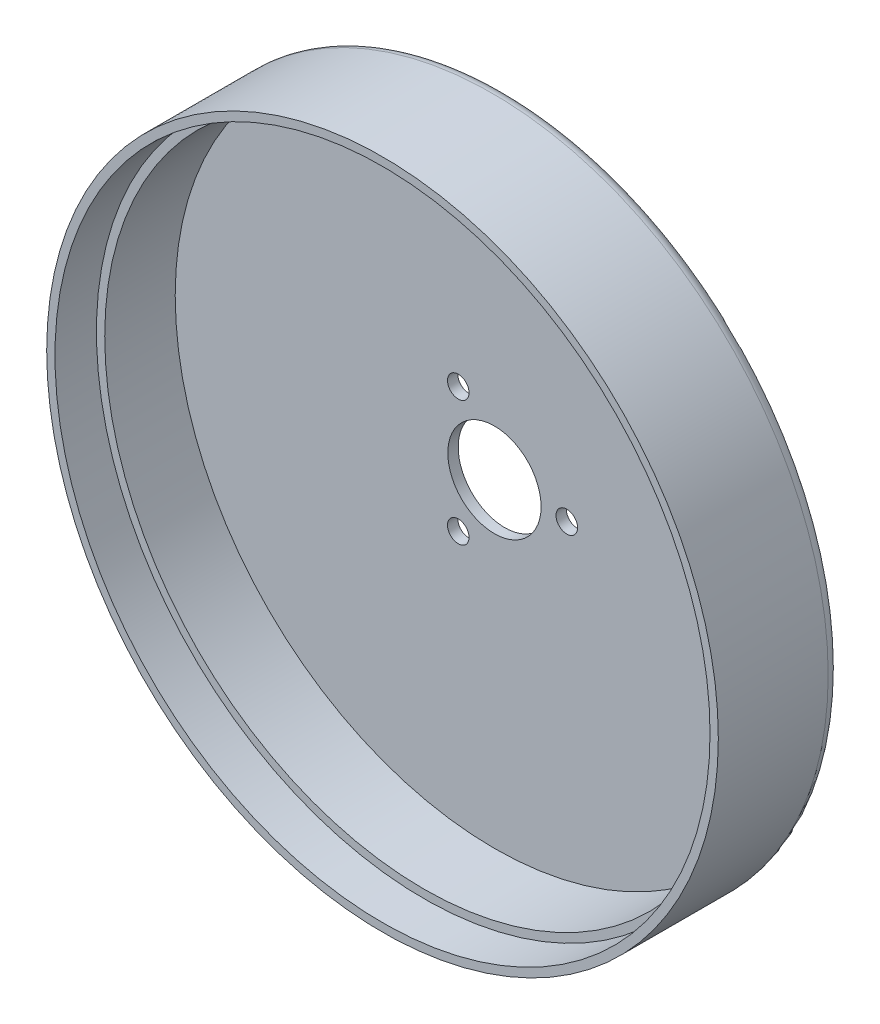
from build123d import *

# Parameters (mm, degrees)
SKETCH1_R           = 81
BOSS_EXTRUDE1_DEPTH = 2.5
SKETCH2_R           = 11.25
CUT_EXTRUDE1_DEPTH  = 3.5
SKETCH3_R           = 2.6
CUT_EXTRUDE2_DEPTH  = 3.5
SKETCH4_R           = 81
SKETCH4_R_2         = 77
BOSS_EXTRUDE2_DEPTH = 27
SKETCH5_R           = 79
CUT_EXTRUDE3_DEPTH  = 10
FILLET1_R           = 3


with BuildPart() as part:
    # Sketch1 → Boss-Extrude1 (new body)
    with BuildSketch(Plane.XY):
        Circle(SKETCH1_R)
    extrude(amount=BOSS_EXTRUDE1_DEPTH)

    # Sketch2 → Cut-Extrude1 (cut, through all)
    with BuildSketch(Plane.XY.offset(2.5)):
        Circle(SKETCH2_R)
    extrude(amount=-CUT_EXTRUDE1_DEPTH, mode=Mode.SUBTRACT)

    # Sketch3 → Cut-Extrude2 (cut, through all)
    with BuildSketch(Plane.XY.offset(2.5)):
        with Locations((17.45, 0)):
            Circle(SKETCH3_R)
        with Locations((-8.725, 15.112143296)):
            Circle(SKETCH3_R)
        with Locations((-8.725, -15.112143296)):
            Circle(SKETCH3_R)
    extrude(amount=-CUT_EXTRUDE2_DEPTH, mode=Mode.SUBTRACT)

    # Sketch4 → Boss-Extrude2 (add)
    with BuildSketch(Plane.XY.offset(2.5)):
        Circle(SKETCH4_R)
        Circle(SKETCH4_R_2, mode=Mode.SUBTRACT)
    extrude(amount=BOSS_EXTRUDE2_DEPTH)

    # Sketch5 → Cut-Extrude3 (cut)
    with BuildSketch(Plane.XY.offset(29.5)):
        Circle(SKETCH5_R)
    extrude(amount=-CUT_EXTRUDE3_DEPTH, mode=Mode.SUBTRACT)

    # Fillet1
    fillet1_edges = [part.edges().sort_by_distance(p)[0] for p in [
        (-81, 0, 0),
    ]]
    fillet(fillet1_edges, radius=FILLET1_R)


solid = part.part
